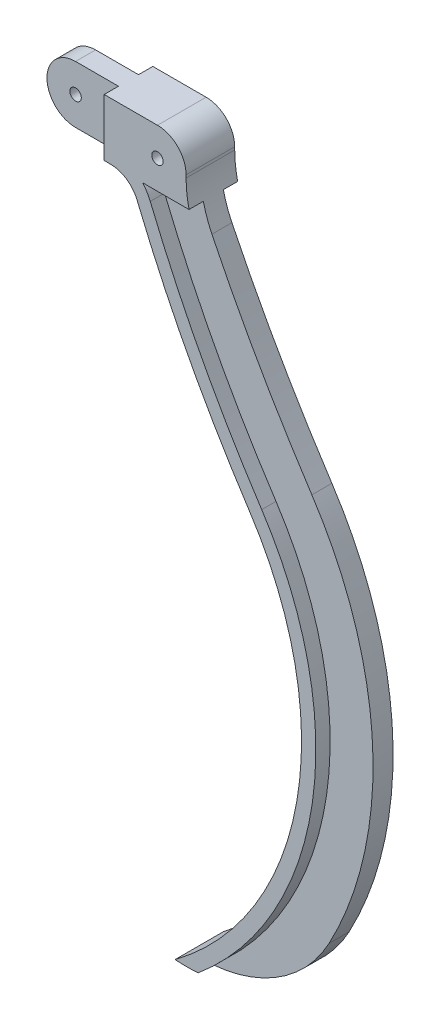
from build123d import *

# Parameters (mm, degrees)
CROQUIS1_R              = 2
SALIENTE_EXTRUIR1_DEPTH = 7
SALIENTE_EXTRUIR2_DEPTH = 5
SALIENTE_EXTRUIR3_DEPTH = 5
SALIENTE_EXTRUIR4_DEPTH = 5
CROQUIS6_R              = 2
CORTAR_EXTRUIR1_DEPTH   = 20
SALIENTE_EXTRUIR5_DEPTH = 5
CROQUIS8_R              = 2
CORTAR_EXTRUIR3_DEPTH   = 20
CORTAR_EXTRUIR4_DEPTH   = 20
CROQUIS10_R             = 2
CORTAR_EXTRUIR5_DEPTH   = 5
CROQUIS12_R             = 2
CORTAR_EXTRUIR6_DEPTH   = 5
CROQUIS13_R             = 2
CORTAR_EXTRUIR7_DEPTH   = 45


with BuildPart() as part:
    # Croquis1 → Saliente-Extruir1 (new body)
    with BuildSketch(Plane.XY):
        with BuildLine():
            Line((0, 161.361306161), (59.639031754, 161.361306161))
            ThreePointArc((59.639031754, 161.361306161), (66.710099565, 158.432373972), (69.639031754, 151.361306161))
            Line((69.639031754, 151.361306161), (69.639031754, 150.370999495))
            ThreePointArc((69.639031754, 150.370999495), (70.657777859, 141.400946832), (73.662123993, 132.887804479))
            ThreePointArc((73.662123993, 132.887804479), (90.138531177, 101.602103147), (108.605347016, 71.44843315))
            ThreePointArc((108.605347016, 71.44843315), (129.868212527, 5.85212568), (114.591350051, -61.390736219))
            ThreePointArc((114.591350051, -61.390736219), (94.163470567, -82.020942746), (65.787006352, -88.15934321))
            ThreePointArc((65.787006352, -88.15934321), (108.340691896, -19.034034767), (91.89683209, 60.456366511))
            ThreePointArc((91.89683209, 60.456366511), (70.390740309, 96.854398001), (52.489257919, 135.15407957))
            ThreePointArc((52.489257919, 135.15407957), (48.807435802, 139.665754791), (43.236427549, 141.361306161))
            Line((43.236427549, 141.361306161), (0, 141.361306161))
            Line((0, 141.361306161), (0, 161.361306161))
        make_face()
        with Locations((59.639031754, 151.361306161)):
            Circle(CROQUIS1_R, mode=Mode.SUBTRACT)
    extrude(amount=SALIENTE_EXTRUIR1_DEPTH)

    # Croquis2 → Saliente-Extruir2 (add)
    with BuildSketch(Plane.XY.offset(7)):
        with BuildLine():
            Line((54.416767437, 141.361306161), (43.236427549, 141.361306161))
            ThreePointArc((43.236427549, 141.361306161), (48.807435802, 139.665754791), (52.489257919, 135.15407957))
            ThreePointArc((52.489257919, 135.15407957), (70.390740309, 96.854398001), (91.89683209, 60.456366511))
            ThreePointArc((91.89683209, 60.456366511), (108.340691896, -19.034034767), (65.787006352, -88.15934321))
            ThreePointArc((65.787006352, -88.15934321), (69.834622147, -88.304656697), (73.881004217, -88.128299745))
            ThreePointArc((73.881004217, -88.128299745), (113.782985393, -16.686288834), (96.073960822, 63.204383171))
            ThreePointArc((96.073960822, 63.204383171), (74.813060375, 99.187440057), (57.115673105, 137.050466275))
            ThreePointArc((57.115673105, 137.050466275), (55.950260204, 139.321108873), (54.416767437, 141.361306161))
        make_face()
    extrude(amount=SALIENTE_EXTRUIR2_DEPTH)

    # Croquis4 → Saliente-Extruir4 (add)
    with BuildSketch(Plane.XY.offset(7)):
        with BuildLine():
            Line((69.639031754, 151.361306161), (69.639031754, 150.370999495))
            ThreePointArc((69.639031754, 150.370999495), (69.896834815, 145.836930406), (70.666920879, 141.361306161))
            Line((70.666920879, 141.361306161), (54.416767437, 141.361306161))
            Line((54.416767437, 141.361306161), (0, 141.361306161))
            Line((0, 141.361306161), (0, 161.361306161))
            Line((0, 161.361306161), (59.639031754, 161.361306161))
            ThreePointArc((59.639031754, 161.361306161), (66.710099565, 158.432373972), (69.639031754, 151.361306161))
        make_face()
    extrude(amount=SALIENTE_EXTRUIR4_DEPTH)

    # Croquis6 → Cortar-Extruir1 (cut)
    with BuildSketch(Plane(origin=(0, 0, 0), x_dir=(-1, 0, 0), z_dir=(0, 0, -1))):
        with Locations((-59.639031754, 151.361306161)):
            Circle(CROQUIS6_R)
    extrude(amount=-CORTAR_EXTRUIR1_DEPTH, mode=Mode.SUBTRACT)



with BuildPart() as body_2:
    # Croquis3 → Saliente-Extruir3 (new body)
    with BuildSketch(Plane(origin=(0, 0, 0), x_dir=(-1, 0, 0), z_dir=(0, 0, -1))):
        with BuildLine():
            Line((-43.236427549, 141.361306161), (-54.416767437, 141.361306161))
            ThreePointArc((-54.416767437, 141.361306161), (-55.950260204, 139.321108873), (-57.115673105, 137.050466275))
            ThreePointArc((-57.115673105, 137.050466275), (-74.813060375, 99.187440057), (-96.073960822, 63.204383171))
            ThreePointArc((-96.073960822, 63.204383171), (-113.782985393, -16.686288834), (-73.881004217, -88.128299745))
            ThreePointArc((-73.881004217, -88.128299745), (-69.834622147, -88.304656697), (-65.787006352, -88.15934321))
            ThreePointArc((-65.787006352, -88.15934321), (-108.340691896, -19.034034767), (-91.89683209, 60.456366511))
            ThreePointArc((-91.89683209, 60.456366511), (-70.390740309, 96.854398001), (-52.489257919, 135.15407957))
            ThreePointArc((-52.489257919, 135.15407957), (-48.807435802, 139.665754791), (-43.236427549, 141.361306161))
        make_face()
    extrude(amount=SALIENTE_EXTRUIR3_DEPTH)


with BuildPart() as part_1:
    add(part.part)

    add(body_2.part)  # Saliente-Extruir5 merges body 2
    # Croquis7 → Saliente-Extruir5 (add)
    with BuildSketch(Plane(origin=(0, 0, 0), x_dir=(-1, 0, 0), z_dir=(0, 0, -1))):
        with BuildLine():
            Line((0, 161.361306161), (-59.639031754, 161.361306161))
            ThreePointArc((-59.639031754, 161.361306161), (-66.710099565, 158.432373972), (-69.639031754, 151.361306161))
            Line((-69.639031754, 151.361306161), (-69.639031754, 150.370999495))
            ThreePointArc((-69.639031754, 150.370999495), (-69.896834815, 145.836930406), (-70.666920879, 141.361306161))
            Line((-70.666920879, 141.361306161), (-54.416767437, 141.361306161))
            Line((-54.416767437, 141.361306161), (0, 141.361306161))
            Line((0, 141.361306161), (0, 161.361306161))
        make_face()
    extrude(amount=SALIENTE_EXTRUIR5_DEPTH)

    # Croquis8 → Cortar-Extruir3 (cut)
    with BuildSketch(Plane.XY.offset(12)):
        with Locations((59.639031754, 151.361306161)):
            Circle(CROQUIS8_R)
    extrude(amount=-CORTAR_EXTRUIR3_DEPTH, mode=Mode.SUBTRACT)

    # Croquis9 → Cortar-Extruir4 (cut)
    with BuildSketch(Plane.XY.offset(12)):
        with BuildLine():
            ThreePointArc((26.006407842, 141.361306161), (16.006407842, 151.361306161), (26.006407842, 161.361306161))
            Line((26.006407842, 161.361306161), (0, 161.361306161))
            Line((0, 161.361306161), (0, 141.361306161))
            Line((0, 141.361306161), (26.006407842, 141.361306161))
        make_face()
    extrude(amount=-CORTAR_EXTRUIR4_DEPTH, mode=Mode.SUBTRACT)

    # Croquis10 → Cortar-Extruir5 (cut)
    with BuildSketch(Plane.XY.offset(12)):
        with BuildLine():
            Line((41.006407842, 161.361306161), (26.006407842, 161.361306161))
            ThreePointArc((26.006407842, 161.361306161), (16.006407842, 151.361306161), (26.006407842, 141.361306161))
            Line((26.006407842, 141.361306161), (41.006407842, 141.361306161))
            Line((41.006407842, 141.361306161), (41.006407842, 161.361306161))
        make_face()
        with Locations((26.006407842, 151.361306161)):
            Circle(CROQUIS10_R, mode=Mode.SUBTRACT)
    extrude(amount=-CORTAR_EXTRUIR5_DEPTH, mode=Mode.SUBTRACT)

    # Croquis12 → Cortar-Extruir6 (cut)
    with BuildSketch(Plane(origin=(0, 0, -5), x_dir=(-1, 0, 0), z_dir=(0, 0, -1))):
        with BuildLine():
            Line((-26.006407842, 161.361306161), (-41.006407842, 161.361306161))
            Line((-41.006407842, 161.361306161), (-41.006407842, 141.361306161))
            Line((-41.006407842, 141.361306161), (-26.006407842, 141.361306161))
            ThreePointArc((-26.006407842, 141.361306161), (-16.006407842, 151.361306161), (-26.006407842, 161.361306161))
        make_face()
        with Locations((-26.006407842, 151.361306161)):
            Circle(CROQUIS12_R, mode=Mode.SUBTRACT)
    extrude(amount=-CORTAR_EXTRUIR6_DEPTH, mode=Mode.SUBTRACT)

    # Croquis13 → Cortar-Extruir7 (cut)
    with BuildSketch(Plane(origin=(0, 0, -5), x_dir=(-1, 0, 0), z_dir=(0, 0, -1))):
        with Locations((-26.006407842, 151.361306161)):
            Circle(CROQUIS13_R)
    extrude(amount=-CORTAR_EXTRUIR7_DEPTH, mode=Mode.SUBTRACT)


solid = part_1.part
